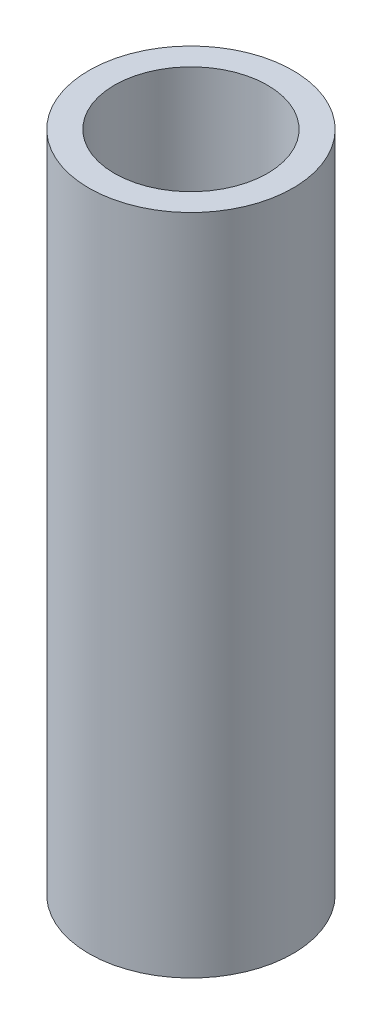
from build123d import *

# Parameters (mm, degrees)
SKETCH1_R           = 4
SKETCH1_R_2         = 3
BOSS_EXTRUDE1_DEPTH = 26


with BuildPart() as part:
    # Sketch1 → Boss-Extrude1 (new body)
    with BuildSketch(Plane(origin=(0, 0, 0), x_dir=(1, 0, 0), z_dir=(0, 1, 0))):
        Circle(SKETCH1_R)
        Circle(SKETCH1_R_2, mode=Mode.SUBTRACT)
    extrude(amount=BOSS_EXTRUDE1_DEPTH)


solid = part.part
